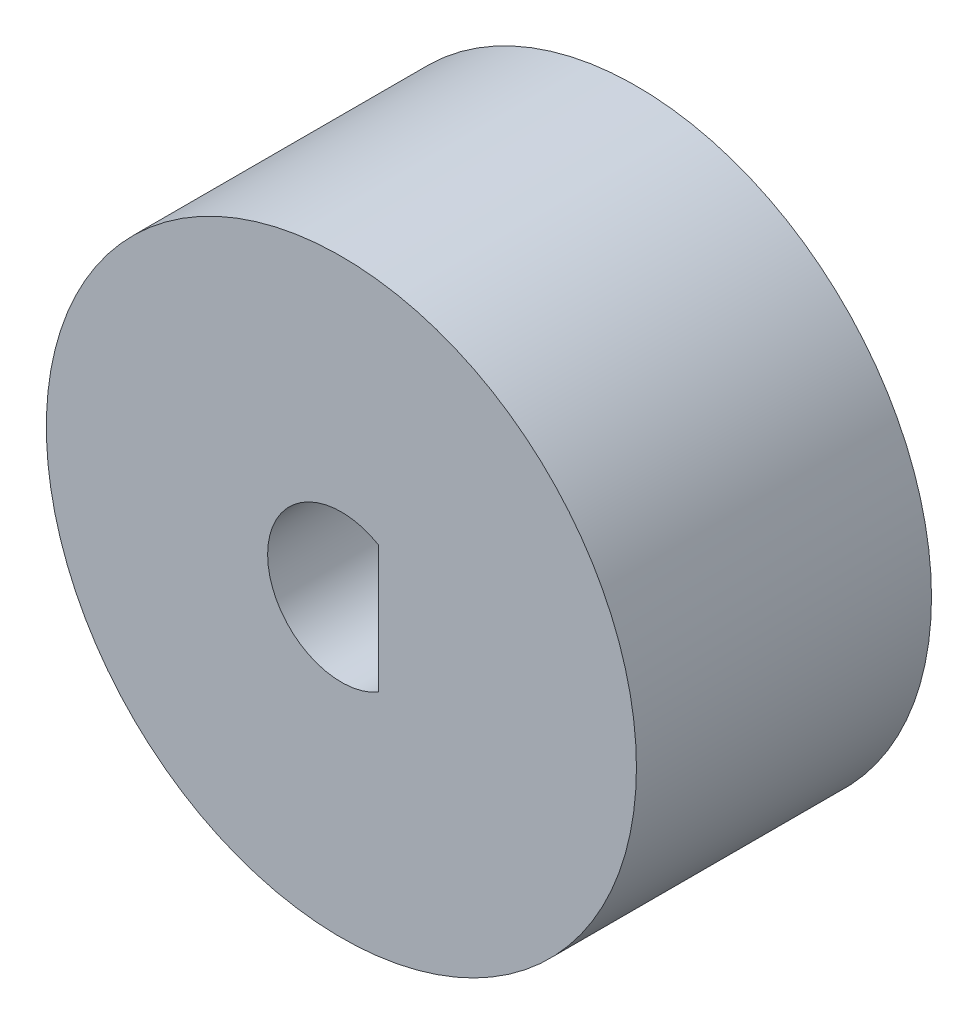
from build123d import *

# Parameters (mm, degrees)
SKETCH1_R           = 50.8
BOSS_EXTRUDE1_DEPTH = 50.8


with BuildPart() as part:
    # Sketch1 → Boss-Extrude1 (new body)
    with BuildSketch(Plane.XY):
        Circle(SKETCH1_R)
        with BuildLine():
            Line((6.35, 10.998522628), (6.35, -10.998522628))
            ThreePointArc((6.35, -10.998522628), (-12.7, 0), (6.35, 10.998522628))
        make_face(mode=Mode.SUBTRACT)
    extrude(amount=BOSS_EXTRUDE1_DEPTH)


solid = part.part
